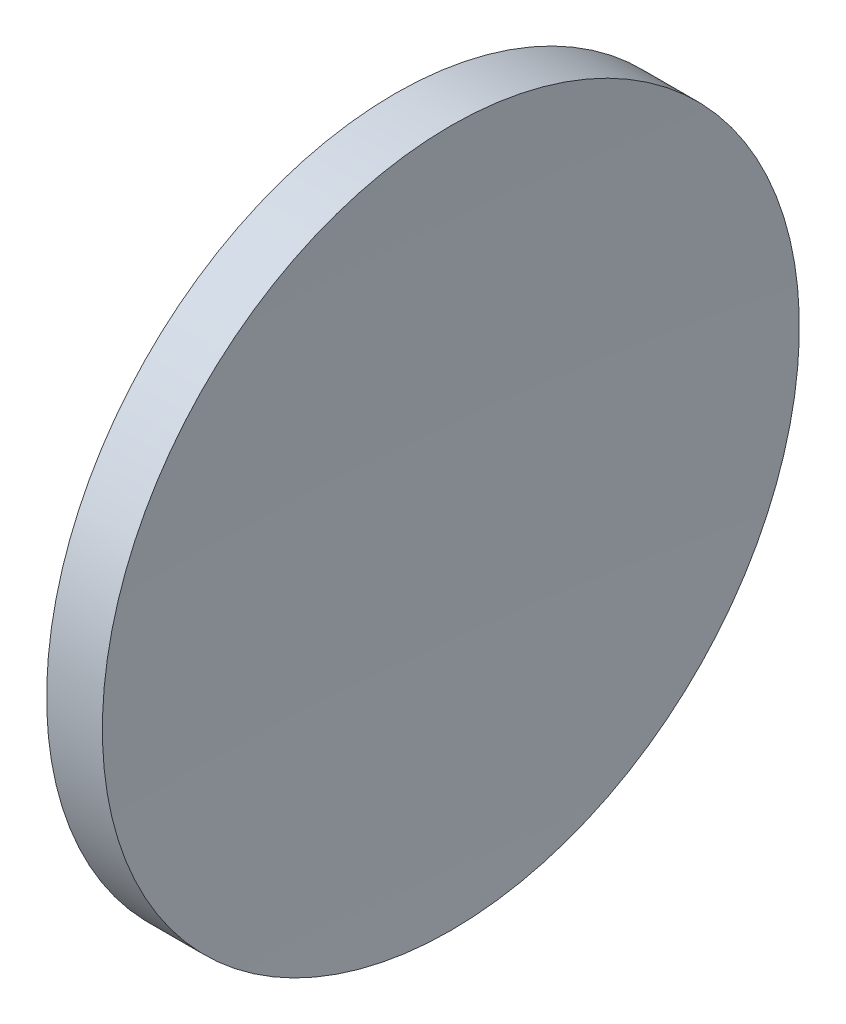
from build123d import *


with BuildPart() as part:
    # 草图1 → 旋转1 (revolve)
    with BuildSketch(Plane.XY):
        with BuildLine():
            Line((124.189724285, 84.241840471), (127.231970953, 84.241840471))
            ThreePointArc((127.231970953, 84.241840471), (126.874577407, 74.732324228), (126.755421316, 65.216840471))
            Line((126.755421316, 65.216840471), (122.855421316, 65.216840471))
            ThreePointArc((122.855421316, 65.216840471), (123.189406251, 74.752706837), (124.189724285, 84.241840471))
        make_face()
    revolve(axis=Axis((115.944491298, 65.216840471, 0), (1, 0, 0)))


solid = part.part
